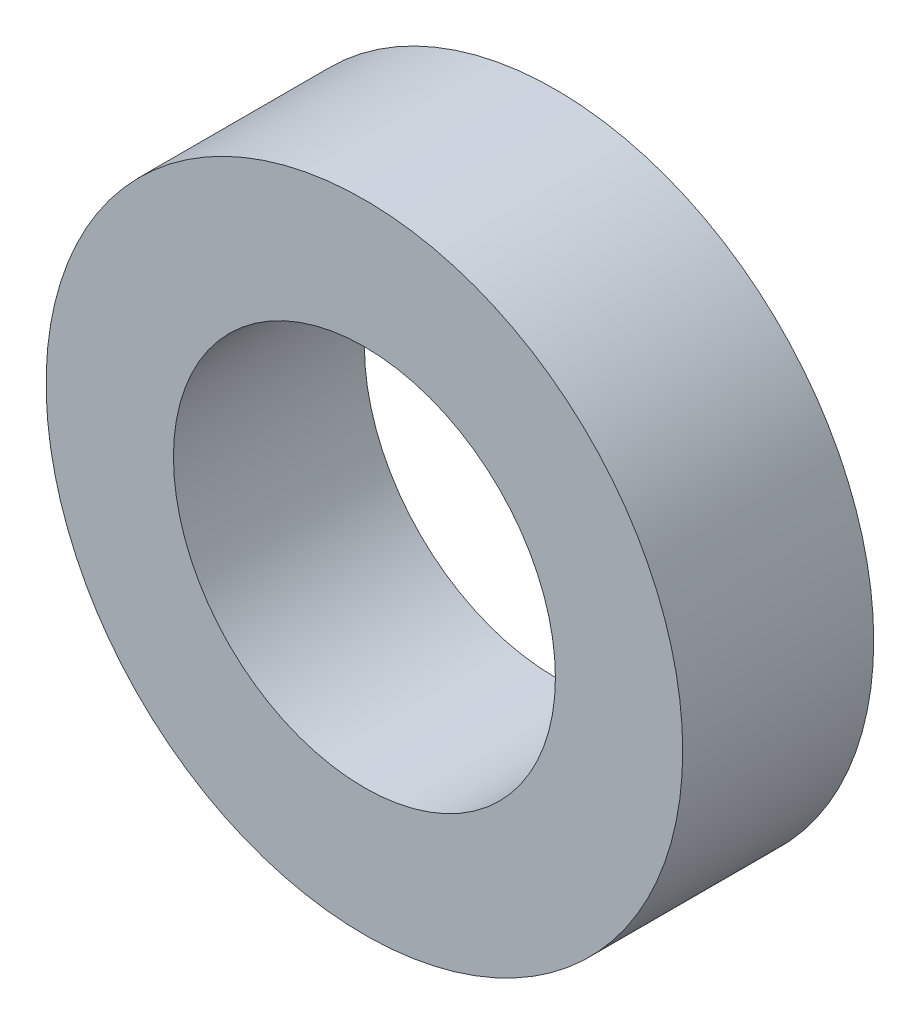
from build123d import *

# Parameters (mm, degrees)
SKETCH_1_R      = 5
SKETCH_1_R_2    = 3
EXTRUDE_1_DEPTH = 3


with BuildPart() as part:
    # 草图1 → 凸台-拉伸1 (new body)
    with BuildSketch(Plane.XY):
        Circle(SKETCH_1_R)
        Circle(SKETCH_1_R_2, mode=Mode.SUBTRACT)
    extrude(amount=EXTRUDE_1_DEPTH)


solid = part.part
